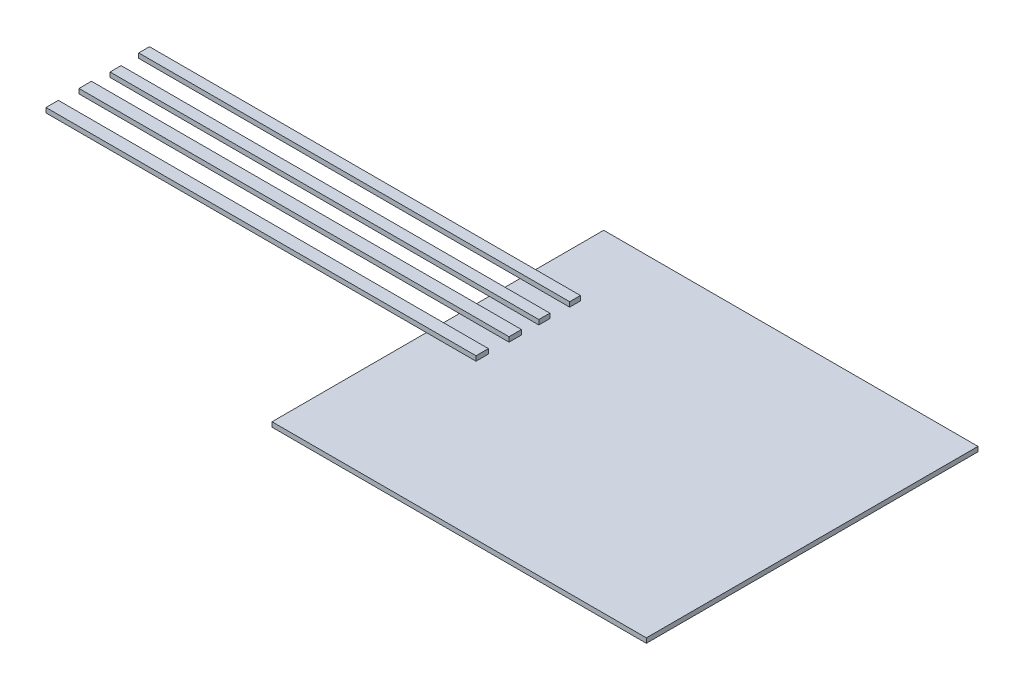
from build123d import *

# Parameters (mm, degrees)
SKETCH1_W           = 39.5
SKETCH1_H           = 35
BOSS_EXTRUDE1_DEPTH = 0.5
SKETCH2_W           = 45.379526607
SKETCH2_H           = 1.305742029
SKETCH2_H_2         = 1.314948277
SKETCH2_W_2         = 45.247695687
SKETCH2_H_3         = 1.164010119
SKETCH2_W_3         = 45.478067193
SKETCH2_H_4         = 1.133268544
BOSS_EXTRUDE2_DEPTH = 0.5


with BuildPart() as part:
    # Sketch1 → Boss-Extrude1 (new body)
    with BuildSketch(Plane(origin=(0, 0, 0), x_dir=(1, 0, 0), z_dir=(0, 1, 0))):
        with Locations((-20.235966577, 4.516998197)):
            Rectangle(SKETCH1_W, SKETCH1_H)
    extrude(amount=BOSS_EXTRUDE1_DEPTH)

    # Sketch2 → Boss-Extrude2 (add)
    with BuildSketch(Plane(origin=(0, 0.5, 0), x_dir=(1, 0, 0), z_dir=(0, 1, 0))):
        with Locations((-57.442922572, 3.963636001)):
            Rectangle(SKETCH2_W, SKETCH2_H)
        with Locations((-57.442922572, 7.450727151)):
            Rectangle(SKETCH2_W, SKETCH2_H_2)
        with Locations((-57.377007112, 10.519214372)):
            Rectangle(SKETCH2_W_2, SKETCH2_H_3)
        with Locations((-57.492192865, 13.759786239)):
            Rectangle(SKETCH2_W_3, SKETCH2_H_4)
    extrude(amount=BOSS_EXTRUDE2_DEPTH)


solid = part.part
